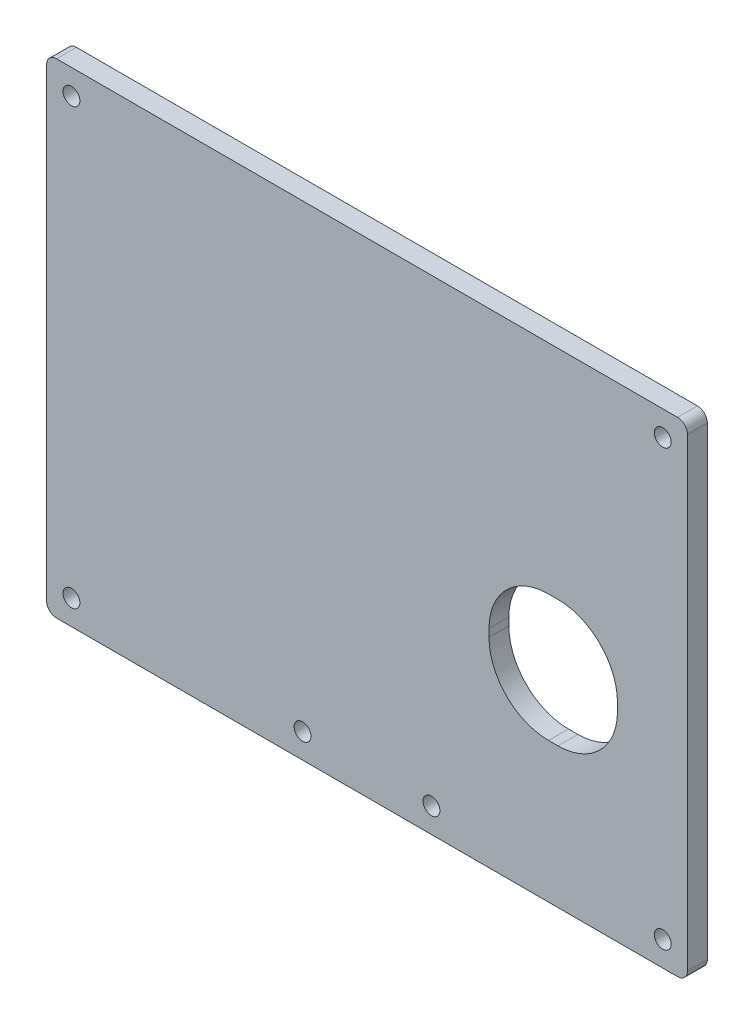
from build123d import *

# Parameters (mm, degrees)
BOSS_EXTRUDE1_DEPTH  = 4
M3_CLEARANCE_HOLE1_D = 3.4
SKETCH4_W            = 25.893128439
SKETCH4_H            = 25.556513708
CUT_EXTRUDE1_DEPTH   = 8
FILLET1_R            = 12


with BuildPart() as part:
    # Sketch1 → Boss-Extrude1 (new body)
    with BuildSketch(Plane.XY):
        with BuildLine():
            Line((-118.577385132, 31.787530767), (6.585636131, 31.787530767))
            ThreePointArc((6.585636131, 31.787530767), (7.999849693, 32.373317205), (8.585636131, 33.787530767))
            Line((8.585636131, 33.787530767), (8.585636131, 127.40770823))
            ThreePointArc((8.585636131, 127.40770823), (7.999849693, 128.821921793), (6.585636131, 129.40770823))
            Line((6.585636131, 129.40770823), (-118.577385132, 129.40770823))
            ThreePointArc((-118.577385132, 129.40770823), (-119.991598694, 128.821921793), (-120.577385132, 127.40770823))
            Line((-120.577385132, 127.40770823), (-120.577385132, 33.787530767))
            ThreePointArc((-120.577385132, 33.787530767), (-119.991598694, 32.373317205), (-118.577385132, 31.787530767))
        make_face()
    extrude(amount=BOSS_EXTRUDE1_DEPTH)

    # M3 Clearance Hole1 (through all)
    with Locations(Plane.XY.offset(4)):
        with Locations((-115.577385132, 124.40770823), (3.585636131, 124.40770823), (-115.577385132, 36.787530767), (-68.995874501, 36.787530767), (-43.015256757, 36.787530767), (3.585636131, 36.787530767)):
            Hole(M3_CLEARANCE_HOLE1_D / 2)

    # Sketch4 → Cut-Extrude1 (cut)
    with BuildSketch(Plane.XY.offset(4)):
        with Locations((-18.472781595, 72.793183927)):
            Rectangle(SKETCH4_W, SKETCH4_H)
    extrude(amount=-CUT_EXTRUDE1_DEPTH, mode=Mode.SUBTRACT)

    # Fillet1
    fillet1_edges = [part.edges().sort_by_distance(p)[0] for p in [
        (-5.526217375, 85.571440781, 2),
        (-5.526217375, 60.014927073, 2),
        (-31.419345814, 60.014927073, 2),
        (-31.419345814, 85.571440781, 2),
    ]]
    fillet(fillet1_edges, radius=FILLET1_R)


solid = part.part
